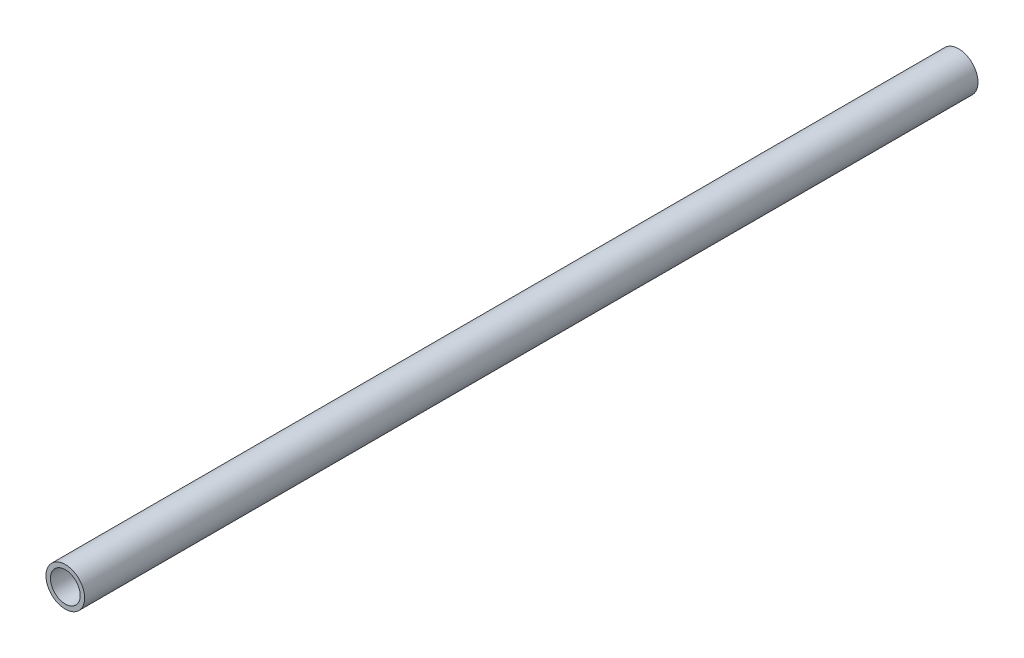
from build123d import *

# Parameters (mm, degrees)
CROQUIS1_R              = 6.5
CROQUIS1_R_2            = 5
SALIENTE_EXTRUIR1_DEPTH = 150


with BuildPart() as part:
    # Croquis1 → Saliente-Extruir1 (new body, symmetric)
    with BuildSketch(Plane.XY):
        Circle(CROQUIS1_R)
        Circle(CROQUIS1_R_2, mode=Mode.SUBTRACT)
    extrude(amount=SALIENTE_EXTRUIR1_DEPTH, both=True)


solid = part.part
